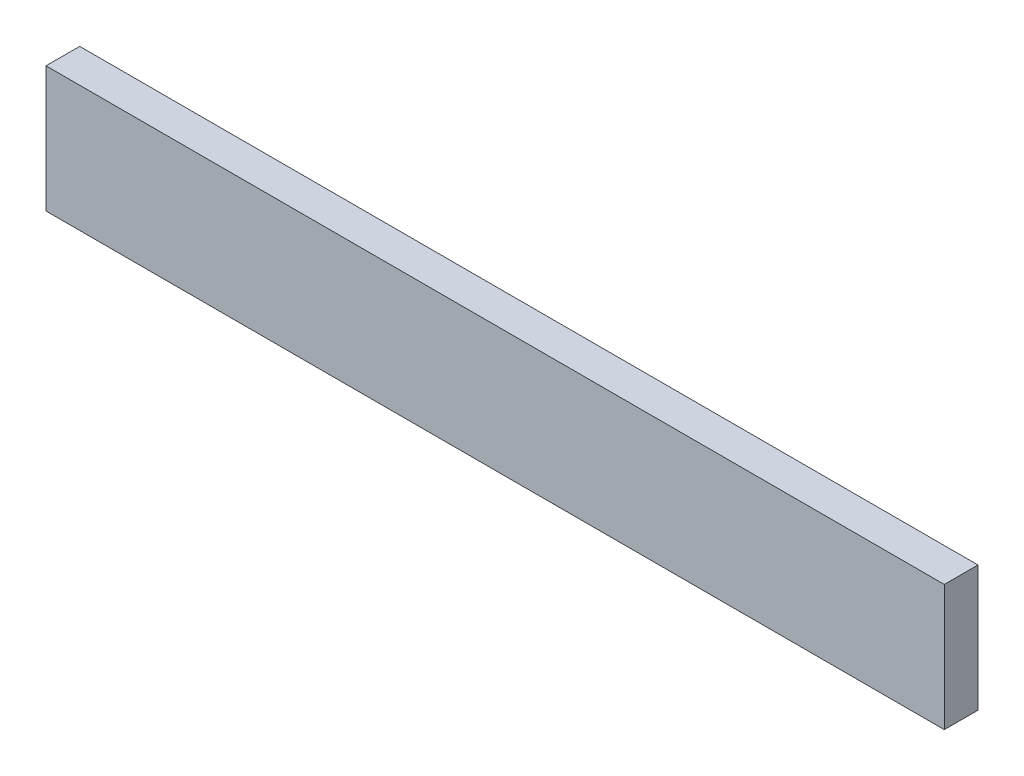
from build123d import *

# Parameters (mm, degrees)
SKETCH1_W           = 80
SKETCH1_H           = 11.2
BOSS_EXTRUDE1_DEPTH = 3


with BuildPart() as part:
    # Sketch1 → Boss-Extrude1 (new body)
    with BuildSketch(Plane.XY):
        with Locations((40, 5.6)):
            Rectangle(SKETCH1_W, SKETCH1_H)
    extrude(amount=BOSS_EXTRUDE1_DEPTH)


solid = part.part
